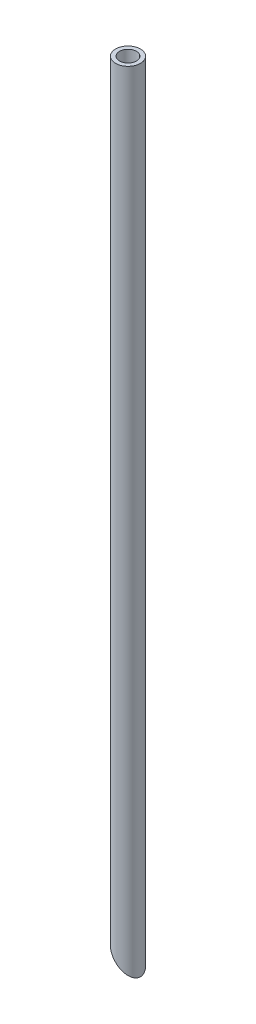
from build123d import *

# Parameters (mm, degrees)
SKETCH1_R               = 0.23622
SKETCH1_R_2             = 0.16002
INNER_POLYIMIDE_DEPTH   = 15
CUT_EXTRUDE1_DEPTH      = 1.23622
CUT_EXTRUDE1_DEPTH_BACK = 1.23622


with BuildPart() as part:
    # Sketch1 → Inner Polyimide (new body)
    with BuildSketch(Plane(origin=(0, 0, 0), x_dir=(1, 0, 0), z_dir=(0, 1, 0))):
        Circle(SKETCH1_R)
        Circle(SKETCH1_R_2, mode=Mode.SUBTRACT)
    extrude(amount=INNER_POLYIMIDE_DEPTH)

    # Sketch2 → Cut-Extrude1 (cut, two sides)
    with BuildSketch(Plane.XY) as cut_extrude1_sk:
        Polygon((0.23622, 0), (-0.23622, 0.47244), (-0.23622, 0), align=None)
    extrude(amount=CUT_EXTRUDE1_DEPTH, mode=Mode.SUBTRACT)
    extrude(cut_extrude1_sk.sketch, amount=-CUT_EXTRUDE1_DEPTH_BACK, mode=Mode.SUBTRACT)


solid = part.part
